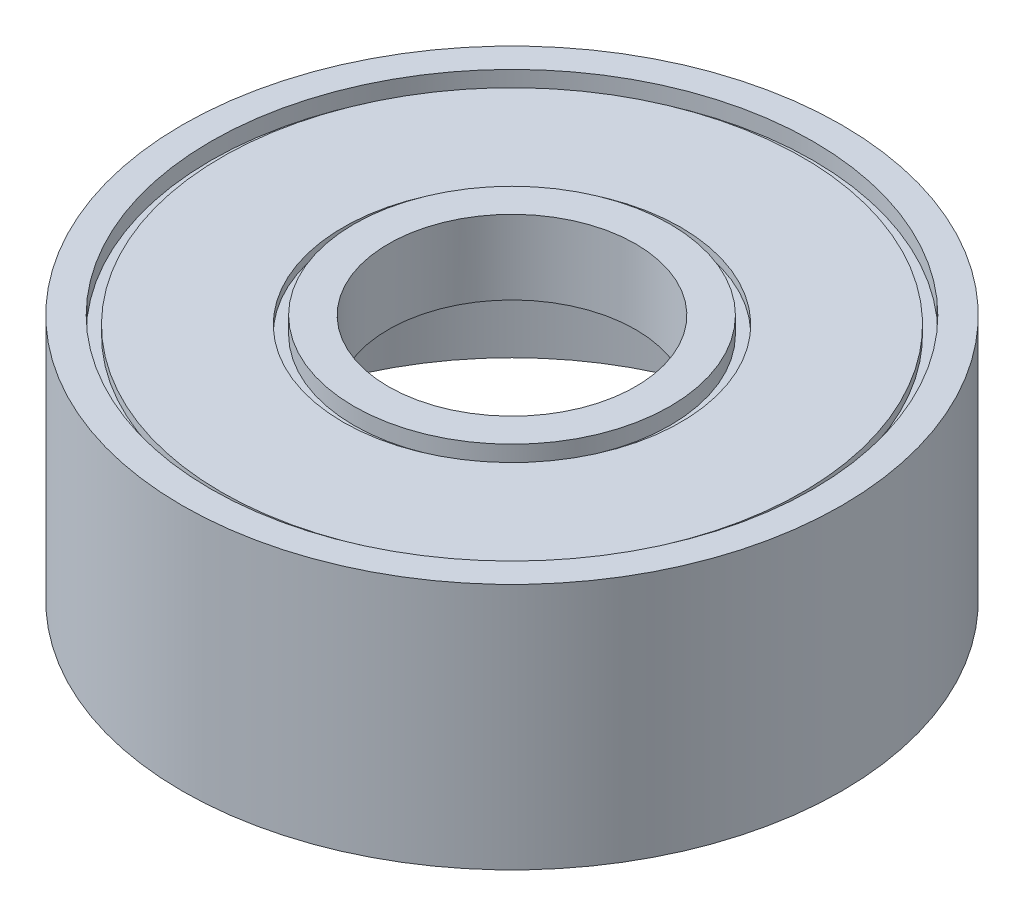
from build123d import *

# Parameters (mm, degrees)
SKETCH1_R           = 4
SKETCH1_R_2         = 1.5
BOSS_EXTRUDE1_DEPTH = 3
SKETCH2_R           = 3.653156204
SKETCH2_R_2         = 1.91674474
CUT_EXTRUDE1_DEPTH  = 0.1
SKETCH4_R           = 2.048114098
SKETCH4_R_2         = 1.91674474
CUT_EXTRUDE6_DEPTH  = 0.1
SKETCH5_R           = 3.653156204
SKETCH5_R_2         = 3.522114118
CUT_EXTRUDE7_DEPTH  = 0.1
SKETCH6_R           = 3.611227951
CUT_EXTRUDE8_DEPTH  = 2.1


with BuildPart() as part:
    # Sketch1 → Boss-Extrude1 (new body)
    with BuildSketch(Plane(origin=(0, 0, 0), x_dir=(1, 0, 0), z_dir=(0, 1, 0))):
        Circle(SKETCH1_R)
        Circle(SKETCH1_R_2, mode=Mode.SUBTRACT)
    extrude(amount=BOSS_EXTRUDE1_DEPTH)

    # Sketch2 → Cut-Extrude1 (cut)
    with BuildSketch(Plane(origin=(0, 3, 0), x_dir=(1, 0, 0), z_dir=(0, 1, 0))):
        Circle(SKETCH2_R)
        Circle(SKETCH2_R_2, mode=Mode.SUBTRACT)
    extrude(amount=-CUT_EXTRUDE1_DEPTH, mode=Mode.SUBTRACT)

    # Sketch4 → Cut-Extrude6 (cut)
    with BuildSketch(Plane(origin=(0, 2.9, 0), x_dir=(1, 0, 0), z_dir=(0, 1, 0))):
        Circle(SKETCH4_R)
        Circle(SKETCH4_R_2, mode=Mode.SUBTRACT)
    extrude(amount=-CUT_EXTRUDE6_DEPTH, mode=Mode.SUBTRACT)

    # Sketch5 → Cut-Extrude7 (cut)
    with BuildSketch(Plane(origin=(0, 2.9, 0), x_dir=(1, 0, 0), z_dir=(0, 1, 0))):
        Circle(SKETCH5_R)
        Circle(SKETCH5_R_2, mode=Mode.SUBTRACT)
    extrude(amount=-CUT_EXTRUDE7_DEPTH, mode=Mode.SUBTRACT)

    # Sketch6 → Cut-Extrude8 (cut)
    with BuildSketch(Plane.XZ):
        Circle(SKETCH6_R)
    extrude(amount=-CUT_EXTRUDE8_DEPTH, mode=Mode.SUBTRACT)


solid = part.part
